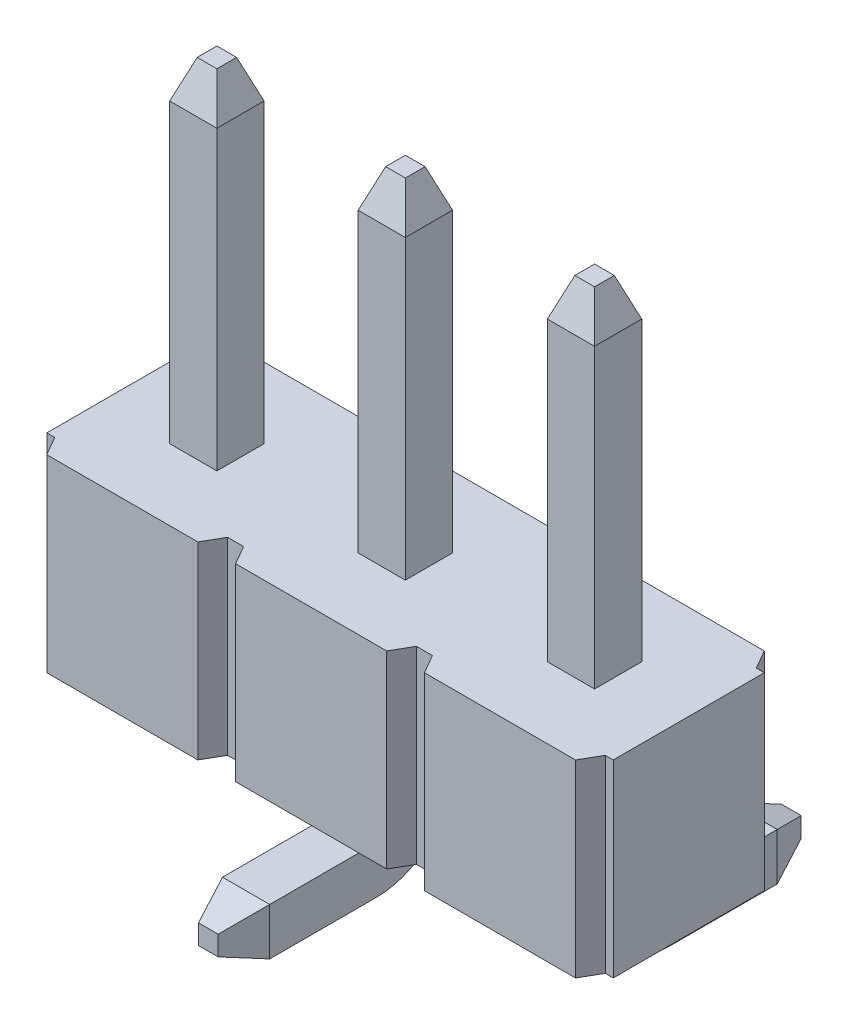
from build123d import *

# Parameters (mm, degrees)
SKETCH1_W                            = 15.24
SKETCH1_H                            = 2.54
BASE_EXTRUDE_DEPTH                   = 1.27
PIN_DEPTH                            = 0.3175
PIN_CHAMFER_SIZE2                    = 0.184896879
PIN_CHAMFER_SIZE                     = 0.508
PIN_PATTERN_COUNT                    = 3
PIN_PATTERN_PITCH                    = 5.08
PIN_CHAMFER_OF_PIN_PATTERN_SIZE2     = 0.184896879
PIN_CHAMFER_OF_PIN_PATTERN_SIZE      = 0.508
PIN_2_DEPTH                          = 0.3175
PIN_2_CHAMFER_SIZE2                  = 0.184896879
PIN_2_CHAMFER_SIZE                   = 0.508
PIN_2_PATTERN_COUNT                  = 3
PIN_2_PATTERN_PITCH                  = 5.08
PIN_2_CHAMFER_OF_PIN_2_PATTERN_SIZE2 = 0.184896879
PIN_2_CHAMFER_OF_PIN_2_PATTERN_SIZE  = 0.508
SV_CUT_DEPTH                         = 4.5
SV_CUT_PATTERN_COUNT                 = 5
SV_CUT_PATTERN_PITCH                 = 2.54
LPATTERN1_COUNT                      = 3
LPATTERN1_PITCH                      = 2.54
SKETCH16_W                           = 7.62
SKETCH16_H                           = 5.30254
CUT_EXTRUDE1_DEPTH                   = 9


with BuildPart() as part:
    # Sketch1 → Base Extrude (new body, symmetric)
    with BuildSketch(Plane(origin=(0, 0, 0), x_dir=(1, 0, 0), z_dir=(0, 1, 0))):
        with Locations((6.35, 0)):
            Rectangle(SKETCH1_W, SKETCH1_H)
    extrude(amount=BASE_EXTRUDE_DEPTH, both=True)

    # Sketch8 → Pin (add, symmetric)
    with BuildSketch(Plane(origin=(0, 0, 0), x_dir=(0, 0, -1), z_dir=(1, 0, 0))):
        with BuildLine():
            Line((0.32004, -1.087), (0.32004, 5.262))
            Line((0.32004, 5.262), (0.135143121, 5.77))
            Line((0.135143121, 5.77), (-0.130063121, 5.77))
            Line((-0.130063121, 5.77), (-0.31496, 5.262))
            Line((-0.31496, 5.262), (-0.31496, -1.214))
            ThreePointArc((-0.31496, -1.214), (-0.01738049, -1.93242049), (0.70104, -2.23))
            Line((0.70104, -2.23), (2.142, -2.23))
            Line((2.142, -2.23), (2.65, -2.045103121))
            Line((2.65, -2.045103121), (2.65, -1.779896879))
            Line((2.65, -1.779896879), (2.142, -1.595))
            Line((2.142, -1.595), (0.82804, -1.595))
            ThreePointArc((0.82804, -1.595), (0.468829755, -1.446210245), (0.32004, -1.087))
        make_face()
    pin = extrude(amount=PIN_DEPTH, both=True)

    # Pin Chamfer
    pin_chamfer_edges = [part.edges().sort_by_distance(p)[0] for p in [
        (0.3175, -1.9125, -2.65),
        (-0.3175, 5.77, -0.00254),
        (-0.3175, -1.9125, -2.65),
        (0.3175, 5.77, -0.00254),
    ]]
    chamfer(pin_chamfer_edges, length=PIN_CHAMFER_SIZE, length2=PIN_CHAMFER_SIZE2)

    # Pin Pattern: Pin ×3
    with Locations(*[(i * PIN_PATTERN_PITCH, 0, 0) for i in range(1, PIN_PATTERN_COUNT)]):
        add(pin)

    # Pin Chamfer of Pin Pattern
    pin_chamfer_of_pin_pattern_edges = [part.edges().sort_by_distance(p)[0] for p in [
        (5.3975, -1.9125, -2.65),
        (4.7625, 5.77, -0.00254),
        (4.7625, -1.9125, -2.65),
        (5.3975, 5.77, -0.00254),
        (10.4775, -1.9125, -2.65),
        (9.8425, 5.77, -0.00254),
        (9.8425, -1.9125, -2.65),
        (10.4775, 5.77, -0.00254),
    ]]
    chamfer(pin_chamfer_of_pin_pattern_edges, length=PIN_CHAMFER_OF_PIN_PATTERN_SIZE, length2=PIN_CHAMFER_OF_PIN_PATTERN_SIZE2)

    # Sketch9 → Pin 2 (add, symmetric)
    with BuildSketch(Plane(origin=(2.54, 0, 0), x_dir=(0, 0, -1), z_dir=(1, 0, 0))):
        with BuildLine():
            Line((-0.32004, -1.087), (-0.32004, 5.262))
            Line((-0.32004, 5.262), (-0.135143121, 5.77))
            Line((-0.135143121, 5.77), (0.130063121, 5.77))
            Line((0.130063121, 5.77), (0.31496, 5.262))
            Line((0.31496, 5.262), (0.31496, -1.214))
            ThreePointArc((0.31496, -1.214), (0.01738049, -1.93242049), (-0.70104, -2.23))
            Line((-0.70104, -2.23), (-2.14454, -2.23))
            Line((-2.14454, -2.23), (-2.65254, -2.045103121))
            Line((-2.65254, -2.045103121), (-2.65254, -1.779896879))
            Line((-2.65254, -1.779896879), (-2.14454, -1.595))
            Line((-2.14454, -1.595), (-0.82804, -1.595))
            ThreePointArc((-0.82804, -1.595), (-0.468829755, -1.446210245), (-0.32004, -1.087))
        make_face()
    pin_2 = extrude(amount=PIN_2_DEPTH, both=True)

    # Pin 2 Chamfer
    pin_2_chamfer_edges = [part.edges().sort_by_distance(p)[0] for p in [
        (2.8575, -1.9125, 2.65254),
        (2.2225, -1.9125, 2.65254),
        (2.2225, 5.77, 0.00254),
        (2.8575, 5.77, 0.00254),
    ]]
    chamfer(pin_2_chamfer_edges, length=PIN_2_CHAMFER_SIZE, length2=PIN_2_CHAMFER_SIZE2)

    # Pin 2 Pattern: Pin 2 ×3
    with Locations(*[(i * PIN_2_PATTERN_PITCH, 0, 0) for i in range(1, PIN_2_PATTERN_COUNT)]):
        add(pin_2)

    # Pin 2 Chamfer of Pin 2 Pattern
    pin_2_chamfer_of_pin_2_pattern_edges = [part.edges().sort_by_distance(p)[0] for p in [
        (7.9375, -1.9125, 2.65254),
        (7.3025, -1.9125, 2.65254),
        (7.3025, 5.77, 0.00254),
        (7.9375, 5.77, 0.00254),
        (13.0175, -1.9125, 2.65254),
        (12.3825, -1.9125, 2.65254),
        (12.3825, 5.77, 0.00254),
        (13.0175, 5.77, 0.00254),
    ]]
    chamfer(pin_2_chamfer_of_pin_2_pattern_edges, length=PIN_2_CHAMFER_OF_PIN_2_PATTERN_SIZE, length2=PIN_2_CHAMFER_OF_PIN_2_PATTERN_SIZE2)

    # Sketch15 → SV Cut (cut, through all)
    with BuildSketch(Plane(origin=(0, 1.27, 0), x_dir=(-1, 0, 0), z_dir=(0, 1, 0))):
        Polygon((-3.556, 1.27), (-3.702646976, 1.016), (-3.917353024, 1.016), (-4.064, 1.27), align=None)
        Polygon((-4.064, -1.27), (-3.917353024, -1.016), (-3.702646976, -1.016), (-3.556, -1.27), align=None)
    sv_cut = extrude(amount=-SV_CUT_DEPTH, mode=Mode.SUBTRACT)

    # SV Cut Pattern: SV Cut ×5
    with Locations(*[(i * SV_CUT_PATTERN_PITCH, 0, 0) for i in range(1, SV_CUT_PATTERN_COUNT)]):
        add(sv_cut, mode=Mode.SUBTRACT)

    # LPattern1: SV Cut ×3
    with Locations(*[(-i * LPATTERN1_PITCH, 0, 0) for i in range(1, LPATTERN1_COUNT)]):
        add(sv_cut, mode=Mode.SUBTRACT)

    # Sketch16 → Cut-Extrude1 (cut, through all)
    with BuildSketch(Plane(origin=(0, 5.77, 0), x_dir=(1, 0, 0), z_dir=(0, 1, 0))):
        with Locations((10.16, -0.00127)):
            Rectangle(SKETCH16_W, SKETCH16_H)
    extrude(amount=-CUT_EXTRUDE1_DEPTH, mode=Mode.SUBTRACT)


solid = part.part
